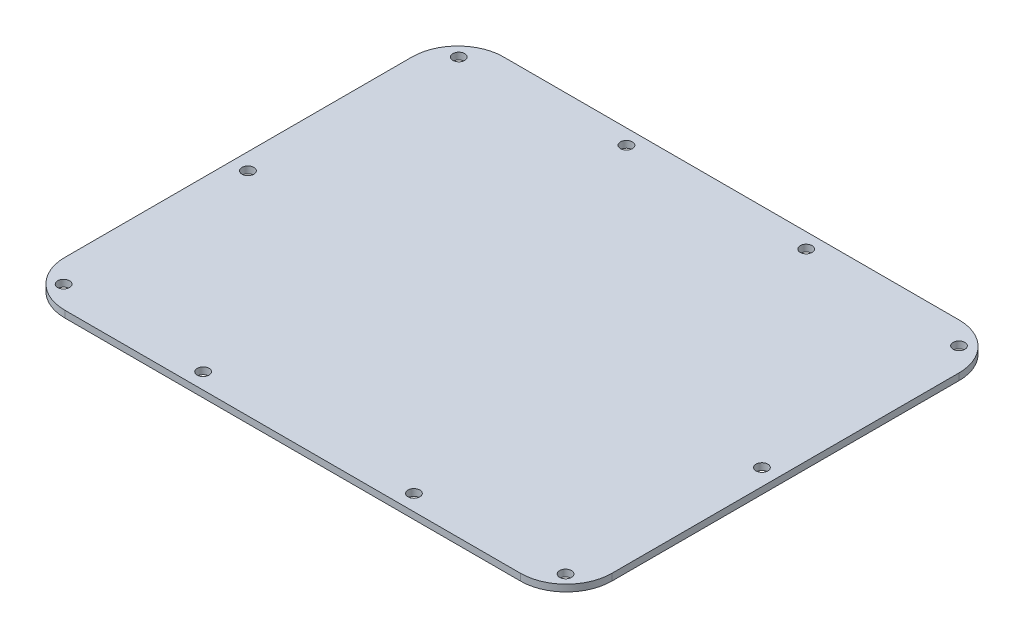
from build123d import *

# Parameters (mm, degrees)
SKETCH2_R           = 2.7813
BOSS_EXTRUDE1_DEPTH = 3.175


with BuildPart() as part:
    # Sketch2 → Boss-Extrude1 (new body)
    with BuildSketch(Plane(origin=(0, 0, 0), x_dir=(1, 0, 0), z_dir=(0, 1, 0))):
        with BuildLine():
            Line((-106.7689, -102.8065), (106.7689, -102.8065))
            ThreePointArc((106.7689, -102.8065), (121.927572332, -96.527572332), (128.2065, -81.3689))
            Line((128.2065, -81.3689), (128.2065, 81.3689))
            ThreePointArc((128.2065, 81.3689), (121.927572332, 96.527572332), (106.7689, 102.8065))
            Line((106.7689, 102.8065), (-106.7689, 102.8065))
            ThreePointArc((-106.7689, 102.8065), (-121.927572332, 96.527572332), (-128.2065, 81.3689))
            Line((-128.2065, 81.3689), (-128.2065, -81.3689))
            ThreePointArc((-128.2065, -81.3689), (-121.927572332, -96.527572332), (-106.7689, -102.8065))
        make_face()
        with Locations((42.1132, 95.7453)):
            Circle(SKETCH2_R, mode=Mode.SUBTRACT)
        with Locations((117.221, 92.2909)):
            Circle(SKETCH2_R, mode=Mode.SUBTRACT)
        with Locations((120.4468, -3.3147)):
            Circle(SKETCH2_R, mode=Mode.SUBTRACT)
        with Locations((117.6274, -92.5195)):
            Circle(SKETCH2_R, mode=Mode.SUBTRACT)
        with Locations((49.403, -95.3643)):
            Circle(SKETCH2_R, mode=Mode.SUBTRACT)
        with Locations((-49.403, -95.3643)):
            Circle(SKETCH2_R, mode=Mode.SUBTRACT)
        with Locations((-117.6274, -92.5195)):
            Circle(SKETCH2_R, mode=Mode.SUBTRACT)
        with Locations((-120.4468, -3.3147)):
            Circle(SKETCH2_R, mode=Mode.SUBTRACT)
        with Locations((-117.221, 92.2909)):
            Circle(SKETCH2_R, mode=Mode.SUBTRACT)
        with Locations((-42.1132, 95.7453)):
            Circle(SKETCH2_R, mode=Mode.SUBTRACT)
    extrude(amount=BOSS_EXTRUDE1_DEPTH)


solid = part.part
